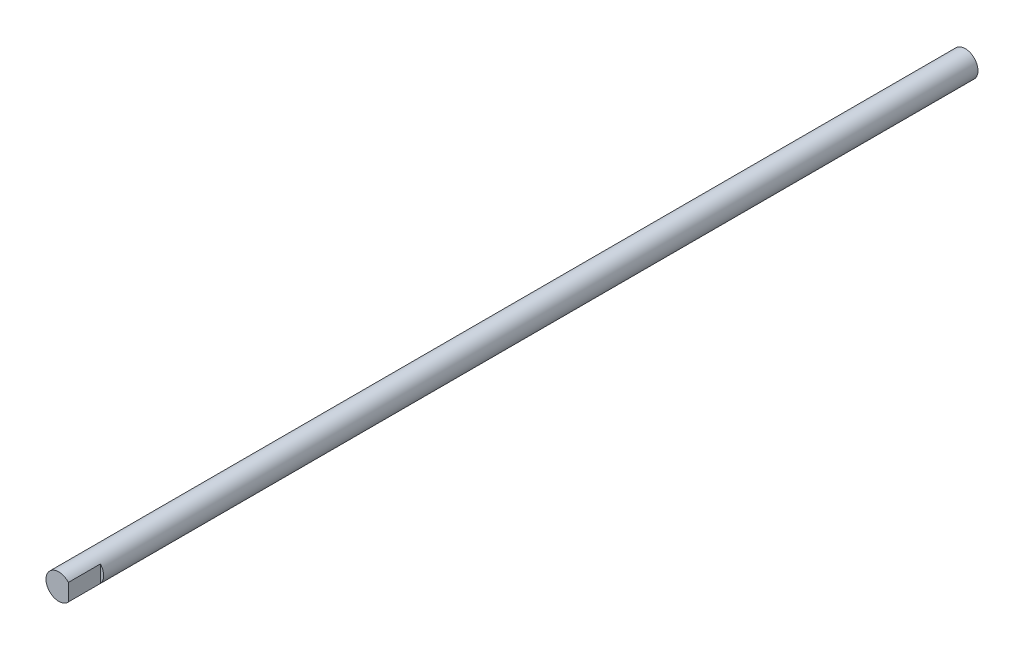
from build123d import *

# Parameters (mm, degrees)
SKETCH1_R             = 4
BOSS_EXTRUDE1_DEPTH   = 283
CROQUIS1_W            = 11.473302211
CROQUIS1_H            = 12.124489633
CORTAR_EXTRUIR1_DEPTH = 10


with BuildPart() as part:
    # Sketch1 → Boss-Extrude1 (new body)
    with BuildSketch(Plane.XY):
        Circle(SKETCH1_R)
    extrude(amount=-BOSS_EXTRUDE1_DEPTH)

    # Croquis1 → Cortar-Extruir1 (cut)
    with BuildSketch(Plane.XY):
        with Locations((8.736651106, -0.765411019)):
            Rectangle(CROQUIS1_W, CROQUIS1_H)
    extrude(amount=-CORTAR_EXTRUIR1_DEPTH, mode=Mode.SUBTRACT)


solid = part.part
